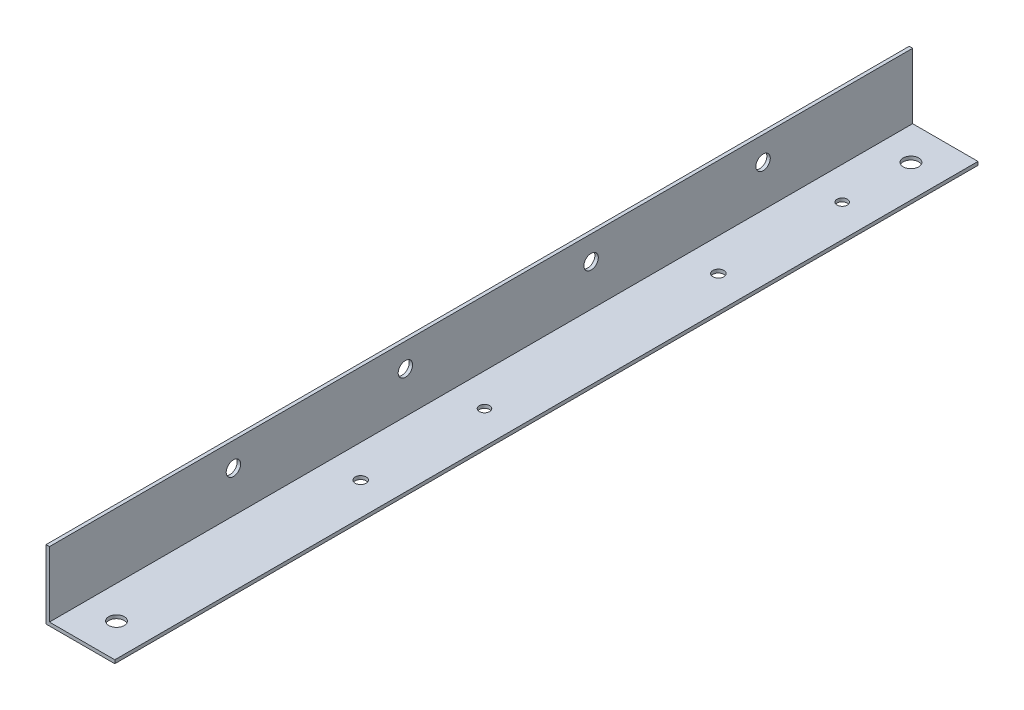
from build123d import *

# Parameters (mm, degrees)
EXTRUDE_1_DEPTH     = 251
SKETCH_3_R          = 1.5
SKETCH_3_R_2        = 1.6
CUT_EXTRUDE_1_DEPTH = 2
SKETCH_4_R          = 2.1
CUT_EXTRUDE_2_DEPTH = 21
SKETCH_5_R          = 2.25
CUT_EXTRUDE_3_DEPTH = 2


with BuildPart() as part:
    # Эскиз1 → Бобышка-Вытянуть1 (new body)
    with BuildSketch(Plane.XY):
        Polygon((0, 0), (0, 20), (1, 20), (1, 1), (20, 1), (20, 0), align=None)
    extrude(amount=EXTRUDE_1_DEPTH)

    # Эскиз3 → Вырез-Вытянуть1 (cut, through all)
    with BuildSketch(Plane(origin=(0, 1, 0), x_dir=(1, 0, 0), z_dir=(0, 1, 0))):
        with Locations((10.5, -134)):
            Circle(SKETCH_3_R)
        with Locations((10.5, -170)):
            Circle(SKETCH_3_R_2)
        with Locations((10.5, -66)):
            Circle(SKETCH_3_R_2)
        with Locations((10.5, -30)):
            Circle(SKETCH_3_R)
    extrude(amount=-CUT_EXTRUDE_1_DEPTH, mode=Mode.SUBTRACT)

    # Эскиз4 → Вырез-Вытянуть2 (cut, through all)
    with BuildSketch(Plane.ZY):
        with Locations((43.5, 13)):
            Circle(SKETCH_4_R)
        with Locations((93.5, 13)):
            Circle(SKETCH_4_R)
        with Locations((147.5, 13)):
            Circle(SKETCH_4_R)
        with Locations((197.5, 13)):
            Circle(SKETCH_4_R)
    extrude(amount=-CUT_EXTRUDE_2_DEPTH, mode=Mode.SUBTRACT)

    # Эскиз5 → Вырез-Вытянуть3 (cut, through all)
    with BuildSketch(Plane(origin=(0, 1, 0), x_dir=(1, 0, 0), z_dir=(0, 1, 0))):
        with Locations((10.5, -10)):
            Circle(SKETCH_5_R)
        with Locations((10.5, -241)):
            Circle(SKETCH_5_R)
    extrude(amount=-CUT_EXTRUDE_3_DEPTH, mode=Mode.SUBTRACT)


solid = part.part
